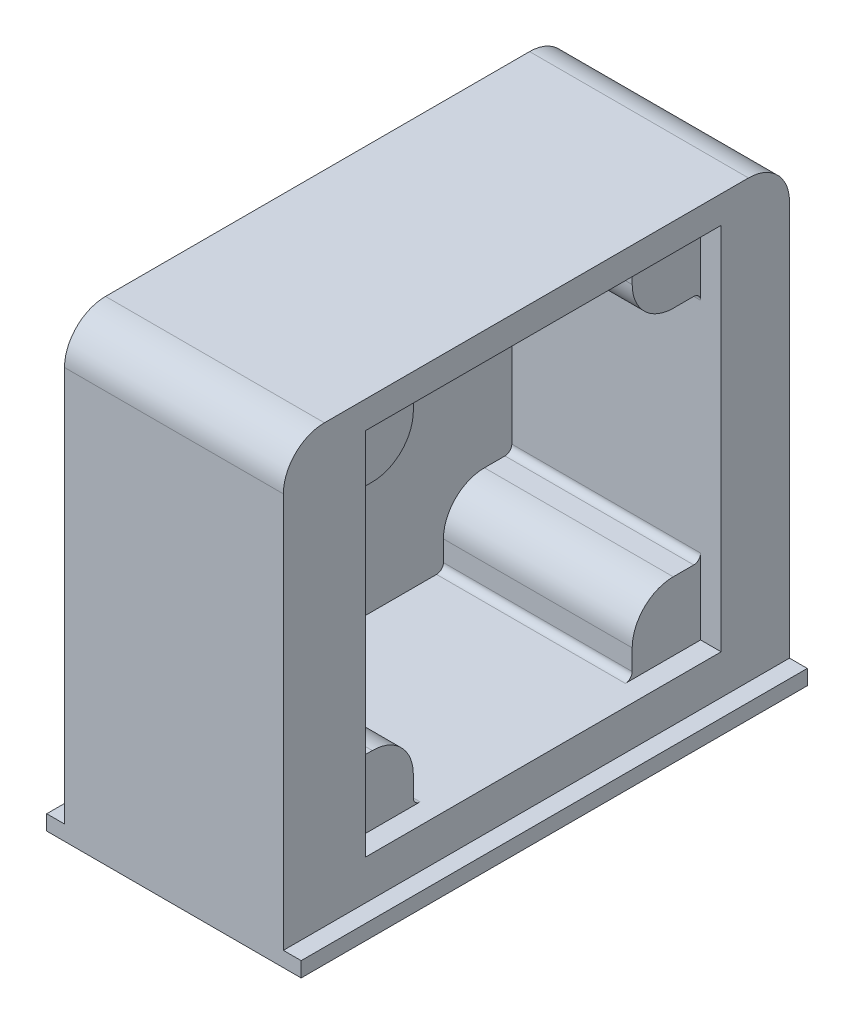
from build123d import *

# Parameters (mm, degrees)
BOSS_EXTRUDE1_DEPTH = 37
SKETCH2_W           = 26
SKETCH2_H           = 27
CUT_EXTRUDE2_DEPTH  = 15.3
SKETCH3_W           = 5
SKETCH3_H           = 5
BOSS_EXTRUDE2_DEPTH = 13.8
FILLET1_R           = 0.5
FILLET2_R           = 3
SKETCH4_W           = 13.8
SKETCH4_H           = 16
CUT_EXTRUDE3_DEPTH  = 1
FILLET3_R           = 1
FILLET4_R           = 3


with BuildPart() as part:
    # Sketch1 → Boss-Extrude1 (new body)
    with BuildSketch(Plane.XY):
        Polygon((-8, -16.5), (-9.3, -16.5), (-9.3, -15.4), (-8, -15.4), (-8, 16.5), (8, 16.5), (8, -15.4), (9.3, -15.4), (9.3, -16.5), (8, -16.5), align=None)
    extrude(amount=BOSS_EXTRUDE1_DEPTH)

    # Sketch2 → Cut-Extrude2 (cut)
    with BuildSketch(Plane.ZY.offset(-8)):
        with Locations((18, 1)):
            Rectangle(SKETCH2_W, SKETCH2_H)
    extrude(amount=CUT_EXTRUDE2_DEPTH, mode=Mode.SUBTRACT)

    # Sketch3 → Boss-Extrude2 (add)
    with BuildSketch(Plane(origin=(-7.3, 0, 0), x_dir=(0, 0, -1), z_dir=(1, 0, 0))):
        with Locations((-28.5, 12)):
            Rectangle(SKETCH3_W, SKETCH3_H)
        with Locations((-7.5, 12)):
            Rectangle(SKETCH3_W, SKETCH3_H)
        with Locations((-7.5, -10)):
            Rectangle(SKETCH3_W, SKETCH3_H)
        with Locations((-28.5, -10)):
            Rectangle(SKETCH3_W, SKETCH3_H)
    extrude(amount=BOSS_EXTRUDE2_DEPTH)

    # Fillet1
    fillet1_edges = [part.edges().sort_by_distance(p)[0] for p in [
        (-0.4, 9.5, 31),
        (-0.4, 9.5, 5),
        (-0.4, -7.5, 31),
        (-0.4, -12.5, 26),
        (-0.4, -7.5, 5),
        (-0.4, -12.5, 10),
    ]]
    fillet(fillet1_edges, radius=FILLET1_R)

    # Fillet2
    fillet2_edges = [part.edges().sort_by_distance(p)[0] for p in [
        (-0.4, 9.5, 26),
        (-0.4, 9.5, 10),
        (-0.4, -7.5, 26),
        (-0.4, -7.5, 10),
    ]]
    fillet(fillet2_edges, radius=FILLET2_R)

    # Sketch4 → Cut-Extrude3 (cut)
    with BuildSketch(Plane.XZ.offset(-14.5)):
        with Locations((-0.4, 18)):
            Rectangle(SKETCH4_W, SKETCH4_H)
    extrude(amount=-CUT_EXTRUDE3_DEPTH, mode=Mode.SUBTRACT)

    # Fillet3
    fillet3_edges = [part.edges().sort_by_distance(p)[0] for p in [
        (-0.4, 15.5, 10),
        (-0.4, 15.5, 26),
    ]]
    fillet(fillet3_edges, radius=FILLET3_R)

    # Fillet4
    fillet4_edges = [part.edges().sort_by_distance(p)[0] for p in [
        (0, 16.5, 0),
        (0, 16.5, 37),
    ]]
    fillet(fillet4_edges, radius=FILLET4_R)


solid = part.part
